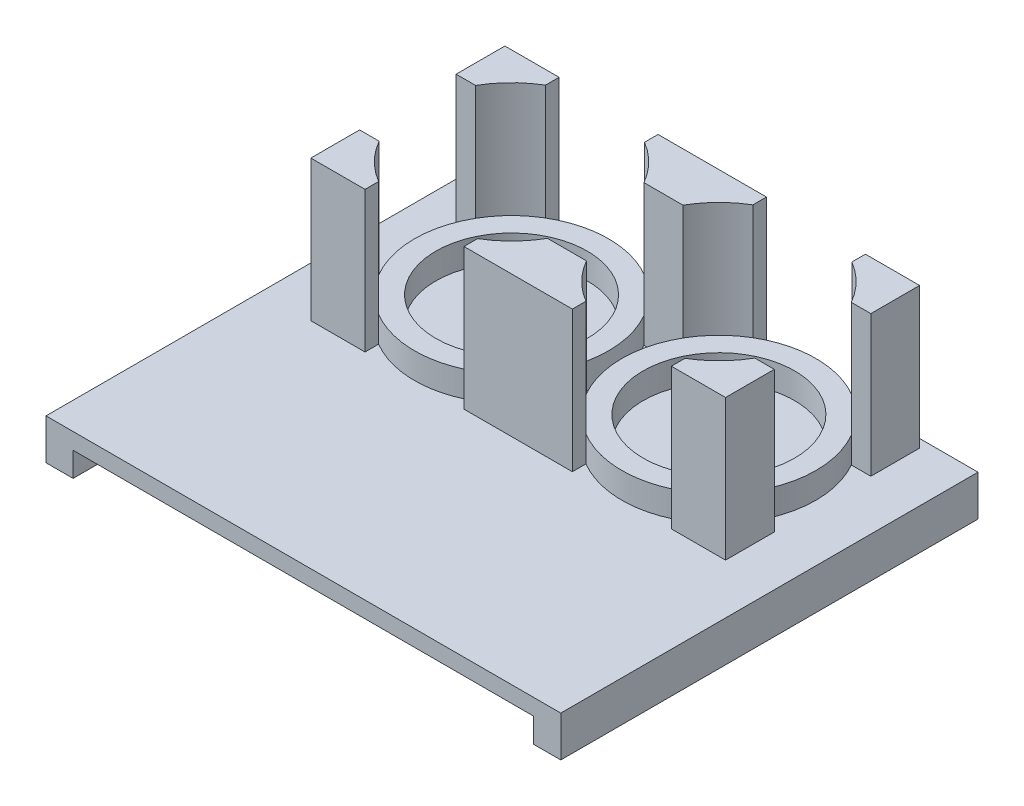
from build123d import *

# Parameters (mm, degrees)
SKETCH1_W           = 85
SKETCH1_H           = 77
BOSS_EXTRUDE1_DEPTH = 3
SKETCH3_R           = 17.907
SKETCH3_R_2         = 13.97
BOSS_EXTRUDE3_DEPTH = 4.7625
BOSS_EXTRUDE7_DEPTH = 26
SKETCH6_W           = 77
SKETCH6_H           = 7.5
BOSS_EXTRUDE8_DEPTH = 5


with BuildPart() as part:
    # Sketch1 → Boss-Extrude1 (new body)
    with BuildSketch(Plane(origin=(0, 0, 0), x_dir=(1, 0, 0), z_dir=(0, 1, 0))):
        Rectangle(SKETCH1_W, SKETCH1_H)
    extrude(amount=BOSS_EXTRUDE1_DEPTH)

    # Sketch3 → Boss-Extrude3 (add)
    with BuildSketch(Plane(origin=(0, 3, 0), x_dir=(1, 0, 0), z_dir=(0, 1, 0))):
        with Locations((19.133331774, 19.048949964)):
            Circle(SKETCH3_R)
        with Locations((19.133331774, 19.048949964)):
            Circle(SKETCH3_R_2, mode=Mode.SUBTRACT)
        with Locations((-19.133331774, 19.048949964)):
            Circle(SKETCH3_R)
        with Locations((-19.133331774, 19.048949964)):
            Circle(SKETCH3_R_2, mode=Mode.SUBTRACT)
    extrude(amount=BOSS_EXTRUDE3_DEPTH)

    # Sketch4 → Boss-Extrude7 (add)
    with BuildSketch(Plane(origin=(0, 3, 0), x_dir=(1, 0, 0), z_dir=(0, 1, 0))):
        with BuildLine():
            ThreePointArc((-34.668002675, 27.955949964), (-31.887785522, 31.618140813), (-28.266663548, 34.451641278))
            Line((-28.266663548, 34.451641278), (-28.266663548, 36.955949964))
            Line((-28.266663548, 36.955949964), (-38.266663548, 36.955949964))
            Line((-38.266663548, 36.955949964), (-38.266663548, 27.955949964))
            Line((-38.266663548, 27.955949964), (-34.668002675, 27.955949964))
        make_face()
        with BuildLine():
            ThreePointArc((-28.266663548, 3.64625865), (-31.887785522, 6.479759115), (-34.668002675, 10.141949964))
            Line((-34.668002675, 10.141949964), (-38.266663548, 10.141949964))
            Line((-38.266663548, 10.141949964), (-38.266663548, 1.141949964))
            Line((-38.266663548, 1.141949964), (-28.266663548, 1.141949964))
            Line((-28.266663548, 1.141949964), (-28.266663548, 3.64625865))
        make_face()
        with BuildLine():
            Line((0, 10.141949964), (-3.598660873, 10.141949964))
            ThreePointArc((-3.598660873, 10.141949964), (-6.378878026, 6.479759115), (-10, 3.64625865))
            Line((-10, 3.64625865), (-10, 1.141949964))
            Line((-10, 1.141949964), (0, 1.141949964))
            Line((0, 1.141949964), (0, 10.141949964))
        make_face()
        with BuildLine():
            ThreePointArc((10, 3.64625865), (6.378878026, 6.479759115), (3.598660873, 10.141949964))
            Line((3.598660873, 10.141949964), (0, 10.141949964))
            Line((0, 10.141949964), (0, 1.141949964))
            Line((0, 1.141949964), (10, 1.141949964))
            Line((10, 1.141949964), (10, 3.64625865))
        make_face()
        with BuildLine():
            Line((0, 27.955949964), (0, 36.955949964))
            Line((0, 36.955949964), (-10, 36.955949964))
            Line((-10, 36.955949964), (-10, 34.451641278))
            ThreePointArc((-10, 34.451641278), (-6.378878026, 31.618140813), (-3.598660873, 27.955949964))
            Line((-3.598660873, 27.955949964), (0, 27.955949964))
        make_face()
        with BuildLine():
            Line((10, 36.955949964), (0, 36.955949964))
            Line((0, 36.955949964), (0, 27.955949964))
            Line((0, 27.955949964), (3.598660873, 27.955949964))
            ThreePointArc((3.598660873, 27.955949964), (6.378878026, 31.618140813), (10, 34.451641278))
            Line((10, 34.451641278), (10, 36.955949964))
        make_face()
        with BuildLine():
            Line((28.266663548, 36.955949964), (28.266663548, 34.451641278))
            ThreePointArc((28.266663548, 34.451641278), (31.887785522, 31.618140813), (34.668002675, 27.955949964))
            Line((34.668002675, 27.955949964), (38.266663548, 27.955949964))
            Line((38.266663548, 27.955949964), (38.266663548, 36.955949964))
            Line((38.266663548, 36.955949964), (28.266663548, 36.955949964))
        make_face()
        with BuildLine():
            ThreePointArc((34.668002675, 10.141949964), (31.887785522, 6.479759115), (28.266663548, 3.64625865))
            Line((28.266663548, 3.64625865), (28.266663548, 1.141949964))
            Line((28.266663548, 1.141949964), (38.266663548, 1.141949964))
            Line((38.266663548, 1.141949964), (38.266663548, 10.141949964))
            Line((38.266663548, 10.141949964), (34.668002675, 10.141949964))
        make_face()
    extrude(amount=BOSS_EXTRUDE7_DEPTH)

    # Sketch6 → Boss-Extrude8 (add)
    with BuildSketch(Plane.ZY.offset(42.5)):
        with Locations((0, -0.75)):
            Rectangle(SKETCH6_W, SKETCH6_H)
    boss_extrude8 = extrude(amount=BOSS_EXTRUDE8_DEPTH)

    # Mirror1: Boss-Extrude8 across plane
    add(boss_extrude8.mirror(Plane(origin=(0, 0, 0), x_dir=(0, 0, 1), z_dir=(1, 0, 0))))


solid = part.part
